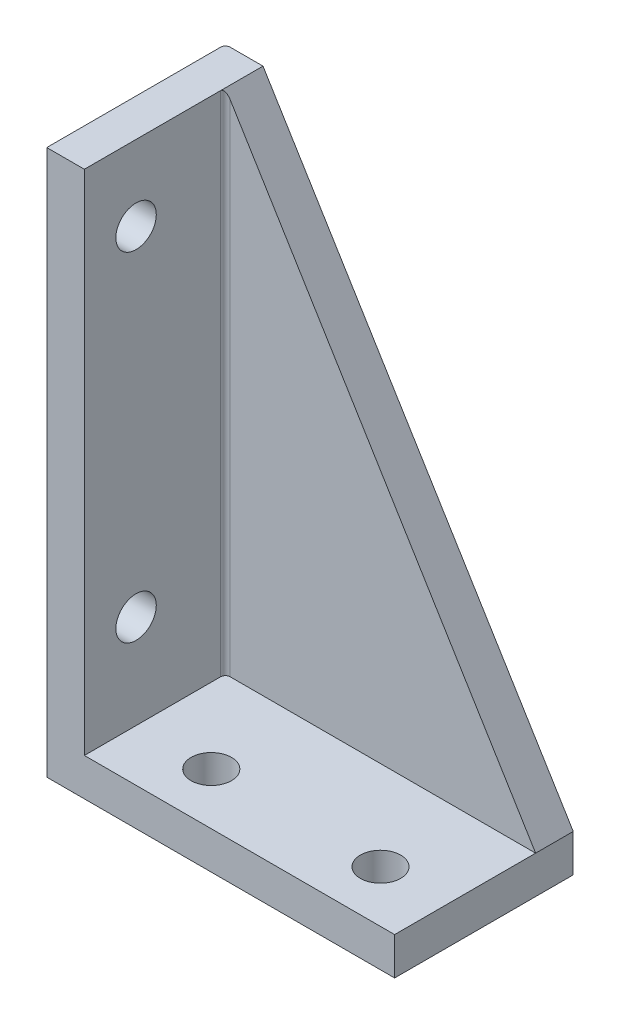
from build123d import *

# Parameters (mm, degrees)
SKETCH1_W               = 37
SKETCH1_H               = 58
BOSS_EXTRUDE1_DEPTH     = 30
SKETCH2_W               = 33
SKETCH2_H               = 13
CUT_EXTRUDE1_DEPTH      = 54
CUT_EXTRUDE2_DEPTH      = 46
M4_CLEARANCE_HOLE1_D    = 4.3
M4_CLEARANCE_HOLE2_D    = 4.3
SKETCH8_W               = 37
SKETCH8_H               = 13
CUT_EXTRUDE3_DEPTH      = 55
CUT_EXTRUDE3_DEPTH_BACK = 10
FILLET1_R               = 0.5
BOSS_EXTRUDE2_DEPTH     = 2


with BuildPart() as part:
    # Sketch1 → Boss-Extrude1 (new body)
    with BuildSketch(Plane.XY):
        with Locations((18.5, 29)):
            Rectangle(SKETCH1_W, SKETCH1_H)
    extrude(amount=BOSS_EXTRUDE1_DEPTH)

    # Sketch2 → Cut-Extrude1 (cut)
    with BuildSketch(Plane(origin=(0, 58, 0), x_dir=(1, 0, 0), z_dir=(0, 1, 0))):
        with Locations((20.5, -6.5)):
            Rectangle(SKETCH2_W, SKETCH2_H)
        with Locations((20.5, -23.5)):
            Rectangle(SKETCH2_W, SKETCH2_H)
    extrude(amount=-CUT_EXTRUDE1_DEPTH, mode=Mode.SUBTRACT)

    # Sketch3 → Cut-Extrude2 (cut)
    with BuildSketch(Plane.XY.offset(13)):
        Polygon((4, 58), (37, 4), (37, 58), align=None)
    extrude(amount=CUT_EXTRUDE2_DEPTH, mode=Mode.SUBTRACT)

    # M4 Clearance Hole1 (through all)
    with Locations(Plane(origin=(4, 0, 0), x_dir=(0, 0, -1), z_dir=(1, 0, 0))):
        with Locations((-26.5, 14), (-26.5, 50)):
            Hole(M4_CLEARANCE_HOLE1_D / 2)

    # M4 Clearance Hole2 (through all)
    with Locations(Plane(origin=(0, 4, 0), x_dir=(1, 0, 0), z_dir=(0, 1, 0))):
        with Locations((12, -26.5), (30, -26.5)):
            Hole(M4_CLEARANCE_HOLE2_D / 2)

    # Sketch8 → Cut-Extrude3 (cut, two sides)
    with BuildSketch(Plane(origin=(0, 4, 0), x_dir=(1, 0, 0), z_dir=(0, 1, 0))) as cut_extrude3_sk:
        with Locations((18.5, -6.5)):
            Rectangle(SKETCH8_W, SKETCH8_H)
    extrude(amount=CUT_EXTRUDE3_DEPTH, mode=Mode.SUBTRACT)
    extrude(cut_extrude3_sk.sketch, amount=-CUT_EXTRUDE3_DEPTH_BACK, mode=Mode.SUBTRACT)

    # Fillet1
    fillet1_edges = [part.edges().sort_by_distance(p)[0] for p in [
        (4, 31, 17),
        (0, 29, 13),
    ]]
    fillet(fillet1_edges, radius=FILLET1_R)

    # Sketch9 → Boss-Extrude2 (add)
    with BuildSketch(Plane.XY.offset(30)):
        Polygon((0, 58), (4, 58), (4, 4), (37, 4), (37, 0), (0, 0), align=None)
    extrude(amount=BOSS_EXTRUDE2_DEPTH)


solid = part.part
